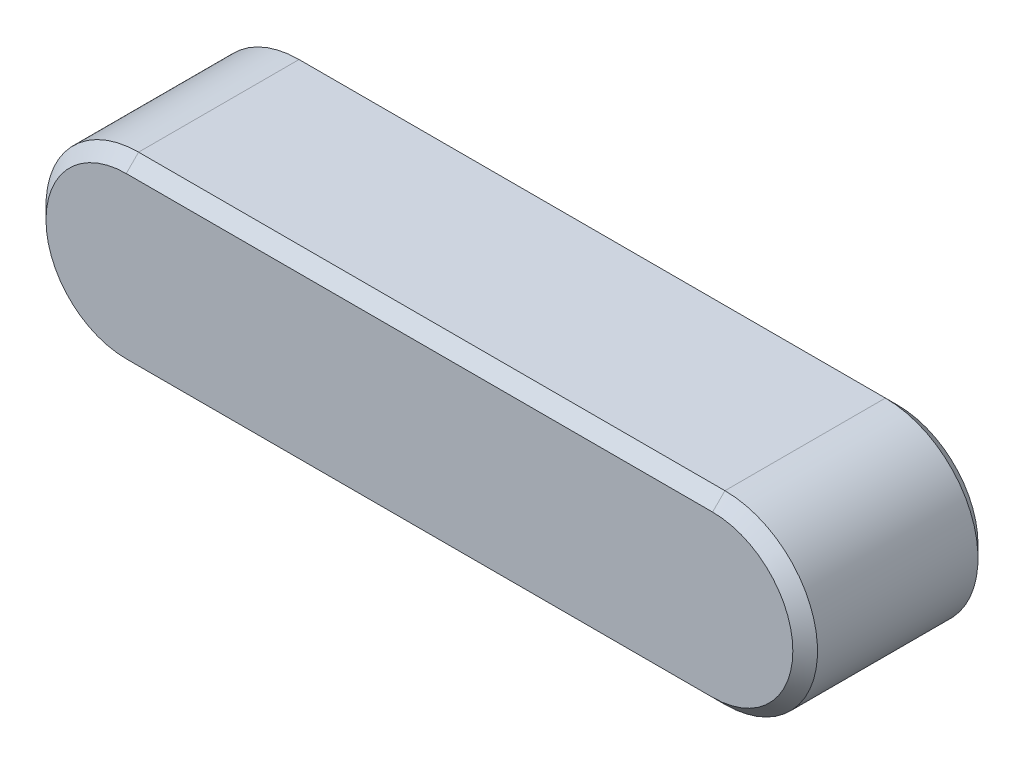
from build123d import *

# Parameters (mm, degrees)
BASEKEY_DEPTH = 3
CHAMFER1_SIZE = 0.4


with BuildPart() as part:
    # Sketch1 → BaseKey (new body, symmetric)
    with BuildSketch(Plane.XY):
        with BuildLine():
            Line((-19, 3), (0, 3))
            ThreePointArc((0, 3), (3, 0), (0, -3))
            Line((0, -3), (-19, -3))
            ThreePointArc((-19, -3), (-22, 0), (-19, 3))
        make_face()
    extrude(amount=BASEKEY_DEPTH, both=True)

    # Chamfer1
    chamfer1_edges = [part.edges().sort_by_distance(p)[0] for p in [
        (3, 0, 3),
        (-9.5, 3, 3),
        (-22, 0, 3),
        (-9.5, 3, -3),
        (3, 0, -3),
        (-9.5, -3, -3),
        (-22, 0, -3),
        (-9.5, -3, 3),
    ]]
    chamfer(chamfer1_edges, length=CHAMFER1_SIZE)


solid = part.part
